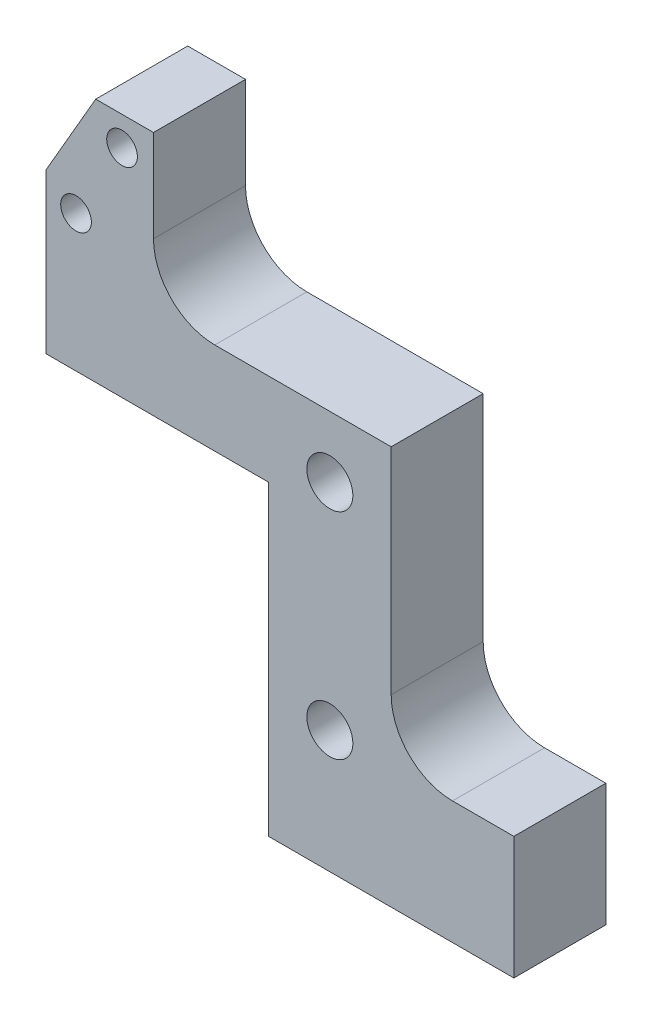
from build123d import *

# Parameters (mm, degrees)
SKETCH1_R                       = 1
BOSS_EXTRUDE1_DEPTH             = 6
FILLET1_R                       = 4
FILLET2_R                       = 4
M3X0_5_TAPPED_HOLE1_D           = 2.5
M3X0_5_TAPPED_HOLE1_DEPTH       = 4
M3X0_5_TAPPED_HOLE1_CSINK_D     = 3.05
M3X0_5_TAPPED_HOLE1_CSINK_ANGLE = 90
M3X0_5_TAPPED_HOLE1_TIP         = 0.751075774
F_2_0_2_DIAMETER_HOLE1_D        = 2
F_2_0_2_DIAMETER_HOLE1_DEPTH    = 3
F_2_0_2_DIAMETER_HOLE1_TIP      = 0.600860619
SKETCH8_R                       = 3
CUT_EXTRUDE1_DEPTH              = 3
SKETCH9_R                       = 1.5
CUT_EXTRUDE2_DEPTH              = 4


with BuildPart() as part:
    # Sketch1 → Boss-Extrude1 (new body)
    with BuildSketch(Plane.XY):
        Polygon((-27.266838493, 36), (-30.5, 30.4), (-30.5, 26), (-30.5, 20), (-16, 20), (-16, 8), (-16, 0), (0, 0), (0, 8), (-8, 8), (-8, 26), (-16, 26), (-23.5, 26), (-23.5, 36), align=None)
        with Locations((-28.55, 28.91)):
            Circle(SKETCH1_R, mode=Mode.SUBTRACT)
        with Locations((-25.55, 34.106152423)):
            Circle(SKETCH1_R, mode=Mode.SUBTRACT)
    extrude(amount=BOSS_EXTRUDE1_DEPTH)

    # Fillet1
    fillet1_edges = [part.edges().sort_by_distance(p)[0] for p in [
        (-23.5, 26, 3),
    ]]
    fillet(fillet1_edges, radius=FILLET1_R)

    # Fillet2
    fillet2_edges = [part.edges().sort_by_distance(p)[0] for p in [
        (-8, 8, 3),
    ]]
    fillet(fillet2_edges, radius=FILLET2_R)

    # M3x0.5 Tapped Hole1
    with Locations(Plane(origin=(0, 0, 0), x_dir=(-1, 0, 0), z_dir=(0, -1, 0))):
        with Locations((13, -3), (3, -3)):
            CounterSinkHole(M3X0_5_TAPPED_HOLE1_D / 2, M3X0_5_TAPPED_HOLE1_CSINK_D / 2, depth=M3X0_5_TAPPED_HOLE1_DEPTH, counter_sink_angle=M3X0_5_TAPPED_HOLE1_CSINK_ANGLE)
            with Locations((0, 0, -(M3X0_5_TAPPED_HOLE1_DEPTH + M3X0_5_TAPPED_HOLE1_TIP / 2))):  # 118° drill point
                Cone(0, M3X0_5_TAPPED_HOLE1_D / 2, M3X0_5_TAPPED_HOLE1_TIP, mode=Mode.SUBTRACT)

    # Ø2.0 (2) Diameter Hole1
    with Locations(Plane(origin=(0, 0, 0), x_dir=(-1, 0, 0), z_dir=(0, -1, 0))):
        with Locations((8, -3)):
            Hole(F_2_0_2_DIAMETER_HOLE1_D / 2, depth=F_2_0_2_DIAMETER_HOLE1_DEPTH)
            with Locations((0, 0, -(F_2_0_2_DIAMETER_HOLE1_DEPTH + F_2_0_2_DIAMETER_HOLE1_TIP / 2))):  # 118° drill point
                Cone(0, F_2_0_2_DIAMETER_HOLE1_D / 2, F_2_0_2_DIAMETER_HOLE1_TIP, mode=Mode.SUBTRACT)

    # Sketch8 → Cut-Extrude1 (cut)
    with BuildSketch(Plane(origin=(0, 0, 0), x_dir=(-1, 0, 0), z_dir=(0, 0, -1))):
        with Locations((12, 22)):
            Circle(SKETCH8_R)
        with Locations((12, 8)):
            Circle(SKETCH8_R)
    extrude(amount=-CUT_EXTRUDE1_DEPTH, mode=Mode.SUBTRACT)

    # Sketch9 → Cut-Extrude2 (cut, through all)
    with BuildSketch(Plane(origin=(0, 0, 3), x_dir=(-1, 0, 0), z_dir=(0, 0, -1))):
        with Locations((12, 22)):
            Circle(SKETCH9_R)
        with Locations((12, 8)):
            Circle(SKETCH9_R)
    extrude(amount=-CUT_EXTRUDE2_DEPTH, mode=Mode.SUBTRACT)


solid = part.part
